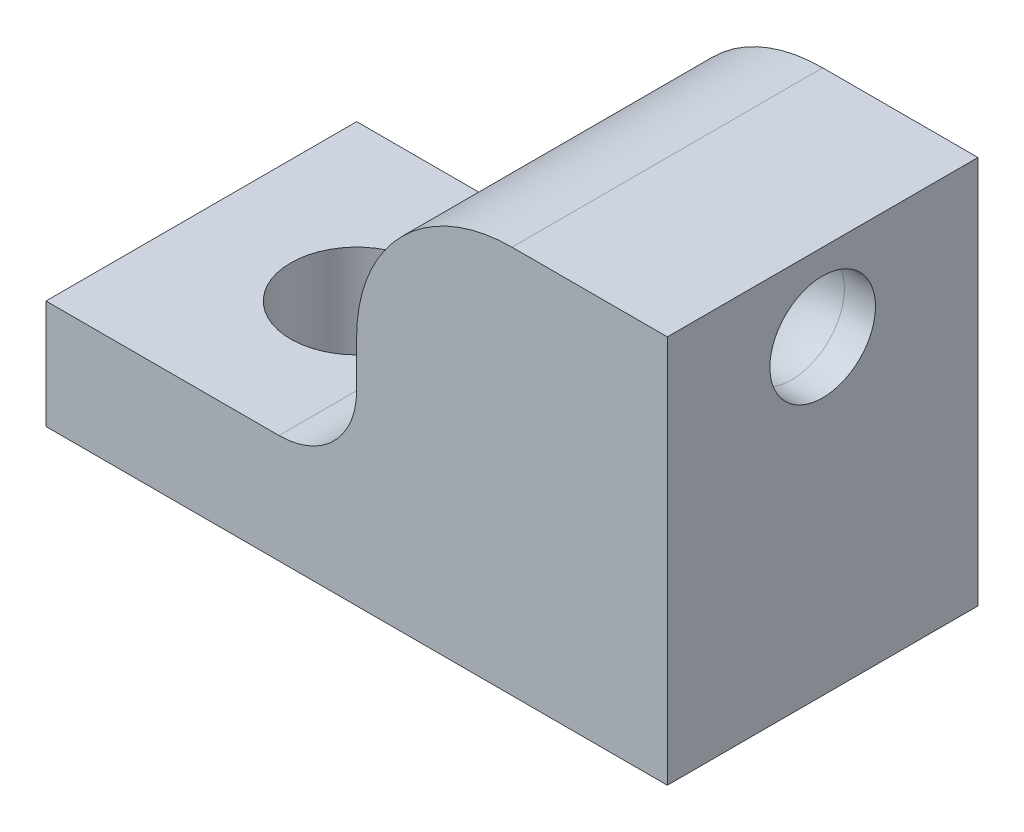
from build123d import *

# Parameters (mm, degrees)
EXTRUDE_1_DEPTH     = 10
SKETCH_2_R          = 4.25
CUT_EXTRUDE_1_DEPTH = 8
SKETCH_4_R          = 3.4
FILLET_1_R          = 5
FILLET_2_R          = 10


with BuildPart() as part:
    # 草圖1 → 填料-伸長1 (new body, symmetric)
    with BuildSketch(Plane.XY):
        Polygon((20, 0), (20, 25), (0, 25), (0, 7), (-20, 7), (-20, 0), align=None)
    extrude(amount=EXTRUDE_1_DEPTH, both=True)

    # 草圖2 → 除料-伸長1 (cut, through all)
    with BuildSketch(Plane(origin=(0, 7, 0), x_dir=(1, 0, 0), z_dir=(0, 1, 0))):
        with Locations((-10, 0)):
            Circle(SKETCH_2_R)
    extrude(amount=-CUT_EXTRUDE_1_DEPTH, mode=Mode.SUBTRACT)

    # 除料-掃出1: sweep along a path in 草圖5
    with BuildLine(Plane(origin=(20, 0, 0), x_dir=(-1, 0, 0), z_dir=(0, 0, -1))) as sweep_1_path:
        Line((10, 0), (10, 12))
        ThreePointArc((10, 12), (7.656854249, 17.656854249), (2, 20))
        Line((2, 20), (0, 20))
    # 草圖4 → 除料-掃出1 (sweep, cut)
    with BuildSketch(Plane.XZ):
        with Locations((10, 0)):
            Circle(SKETCH_4_R)
    sweep(path=sweep_1_path.line, mode=Mode.SUBTRACT)

    # 圓角1
    fillet_1_edges = [part.edges().sort_by_distance(p)[0] for p in [
        (0, 7, 0),
    ]]
    fillet(fillet_1_edges, radius=FILLET_1_R)

    # 圓角2
    fillet_2_edges = [part.edges().sort_by_distance(p)[0] for p in [
        (0, 25, 0),
    ]]
    fillet(fillet_2_edges, radius=FILLET_2_R)


solid = part.part
